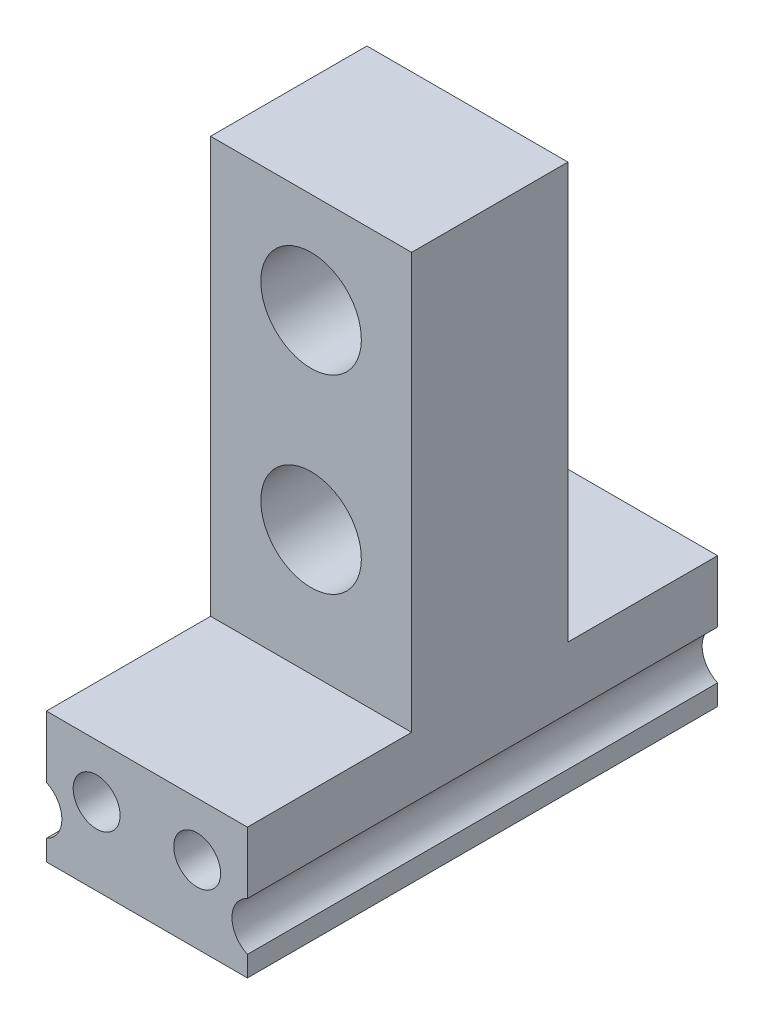
from build123d import *

# Parameters (mm, degrees)
SKETCH_6_W          = 18
SKETCH_6_H          = 37.22
SKETCH_6_R          = 4.5
SKETCH_6_R_2        = 2.1
EXTRUDE_2_DEPTH     = 42.1
SKETCH_8_W          = 14.7
SKETCH_8_H          = 37.22
SKETCH_8_W_2        = 13.4
CUT_EXTRUDE_1_DEPTH = 42.1


with BuildPart() as part:
    # 草图6 → 凸台-拉伸2 (new body)
    with BuildSketch(Plane.XY):
        with Locations((424.099665512, 777.503186937)):
            Rectangle(SKETCH_6_W, SKETCH_6_H)
        with Locations((424.099665512, 770.113186937)):
            Circle(SKETCH_6_R, mode=Mode.SUBTRACT)
        with Locations((424.099665512, 787.113186937)):
            Circle(SKETCH_6_R, mode=Mode.SUBTRACT)
        with BuildLine():
            ThreePointArc((433.099665512, 753.358417872), (431.714665512, 751.193186937), (433.099665512, 749.027956002))
            Line((433.099665512, 749.027956002), (433.099665512, 747.193186937))
            Line((433.099665512, 747.193186937), (415.099665512, 747.193186937))
            Line((415.099665512, 747.193186937), (415.099665512, 749.027956002))
            ThreePointArc((415.099665512, 749.027956002), (416.484665512, 751.193186937), (415.099665512, 753.358417872))
            Line((415.099665512, 753.358417872), (415.099665512, 758.893186937))
            Line((415.099665512, 758.893186937), (433.099665512, 758.893186937))
            Line((433.099665512, 758.893186937), (433.099665512, 753.358417872))
        make_face()
        with Locations((428.599665512, 754.093186937)):
            Circle(SKETCH_6_R_2, mode=Mode.SUBTRACT)
        with Locations((419.599665512, 754.093186937)):
            Circle(SKETCH_6_R_2, mode=Mode.SUBTRACT)
    extrude(amount=EXTRUDE_2_DEPTH)

    # 草图8 → 切除-拉伸1 (cut)
    with BuildSketch(Plane(origin=(433.099665512, 0, 0), x_dir=(0, 0, -1), z_dir=(1, 0, 0))):
        with Locations((-34.75, 777.503186937)):
            Rectangle(SKETCH_8_W, SKETCH_8_H)
        with Locations((-6.7, 777.503186937)):
            Rectangle(SKETCH_8_W_2, SKETCH_8_H)
    extrude(amount=-CUT_EXTRUDE_1_DEPTH, mode=Mode.SUBTRACT)


solid = part.part
